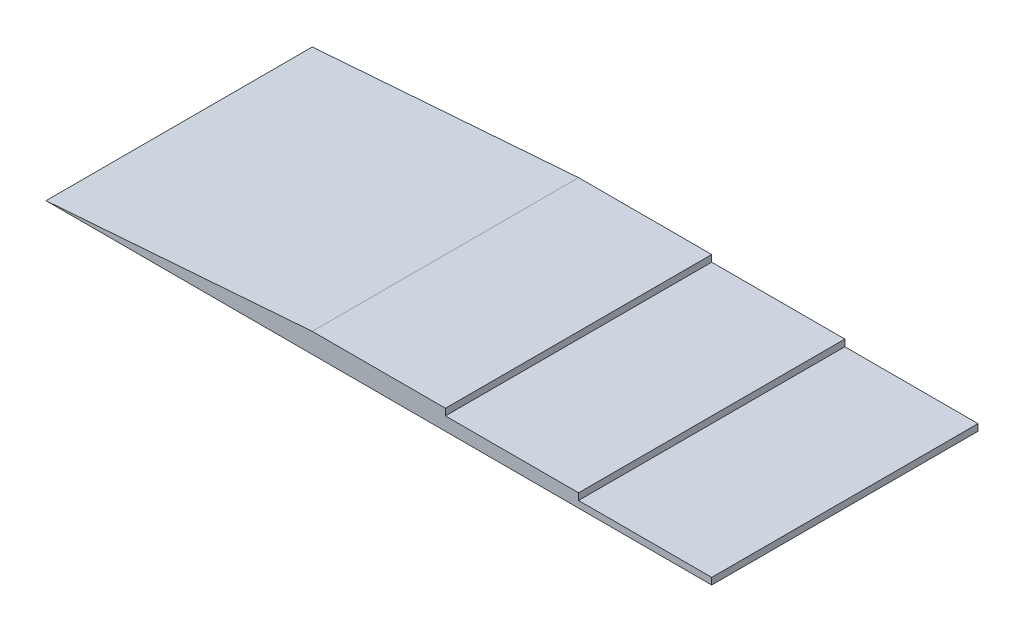
from build123d import *

# Parameters (mm, degrees)
BOSS_EXTRUDE3_DEPTH = 2000


with BuildPart() as part:
    # Sketch1 → Boss-Extrude3 (new body)
    with BuildSketch(Plane.XY):
        Polygon((0, -50), (3000, -50), (3000, 0), (2000, 0), (2000, 50), (1000, 50), (1000, 100), (0, 100), align=None)
        Polygon((0, 100), (-2000, -50), (0, -50), align=None)
    extrude(amount=-BOSS_EXTRUDE3_DEPTH)


solid = part.part
